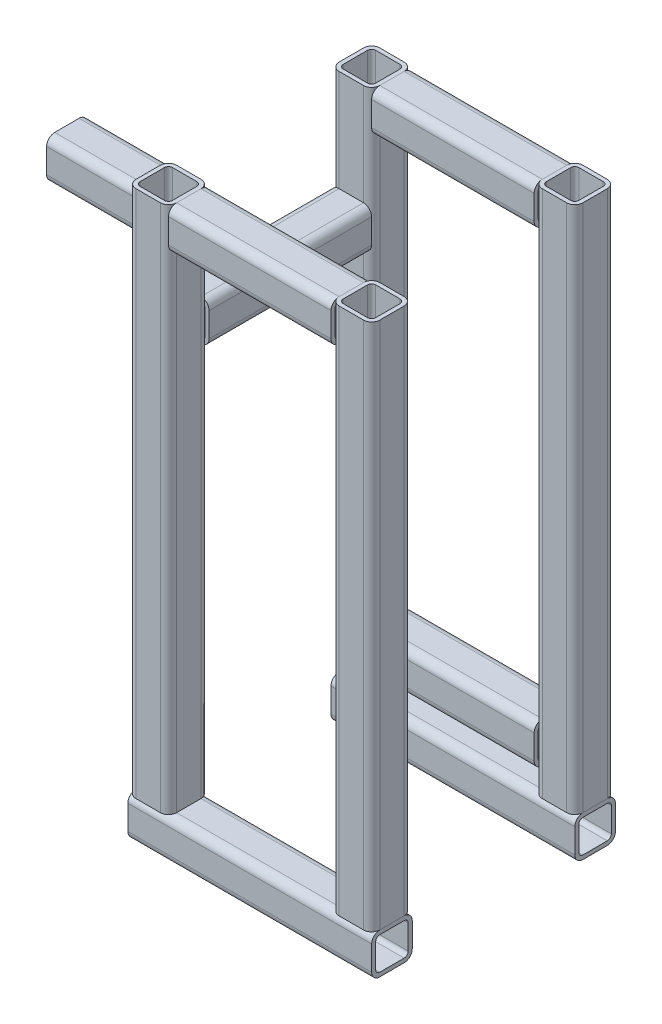
from build123d import *

# Parameters (mm, degrees)
SQUARE_TUBE_40_X_40_X_4_1_DEPTH      = 220
SQUARE_TUBE_40_X_40_X_4_1_DEPTH_BACK = 20
SQUARE_TUBE_40_X_40_X_4_1_2_DEPTH    = 240
SQUARE_TUBE_40_X_40_X_4_1_3_DEPTH    = 541
SQUARE_TUBE_40_X_40_X_4_1_4_DEPTH    = 541
SQUARE_TUBE_40_X_40_X_4_1_5_DEPTH    = 541
SQUARE_TUBE_40_X_40_X_4_1_6_DEPTH    = 541
SQUARE_TUBE_40_X_40_X_4_1_7_DEPTH    = 202
SQUARE_TUBE_40_X_40_X_4_1_8_DEPTH    = 202
SQUARE_TUBE_40_X_40_X_4_1_9_DEPTH    = 202
SQUARE_TUBE_40_X_40_X_4_1_10_DEPTH   = 201
SQUARE_TUBE_40_X_40_X_4_1_11_DEPTH   = 202


with BuildPart() as part:
    # Sketch1 → Square tube 40 X 40 X 4(1) (new, two sides)
    with BuildSketch(Plane(origin=(0, 0, 200), x_dir=(0, 0, -1), z_dir=(1, 0, 0))) as square_tube_40_x_40_x_4_1_sk:
        with BuildLine():
            Line((-12, -20), (12, -20))
            ThreePointArc((12, -20), (17.656854249, -17.656854249), (20, -12))
            Line((20, -12), (20, 12))
            ThreePointArc((20, 12), (17.656854249, 17.656854249), (12, 20))
            Line((12, 20), (-12, 20))
            ThreePointArc((-12, 20), (-17.656854249, 17.656854249), (-20, 12))
            Line((-20, 12), (-20, -12))
            ThreePointArc((-20, -12), (-17.656854249, -17.656854249), (-12, -20))
        make_face()
        with BuildLine():
            Line((-12, -16), (12, -16))
            ThreePointArc((12, -16), (14.828427125, -14.828427125), (16, -12))
            Line((16, -12), (16, 12))
            ThreePointArc((16, 12), (14.828427125, 14.828427125), (12, 16))
            Line((12, 16), (-12, 16))
            ThreePointArc((-12, 16), (-14.828427125, 14.828427125), (-16, 12))
            Line((-16, 12), (-16, -12))
            ThreePointArc((-16, -12), (-14.828427125, -14.828427125), (-12, -16))
        make_face(mode=Mode.SUBTRACT)
    extrude(amount=SQUARE_TUBE_40_X_40_X_4_1_DEPTH)
    extrude(square_tube_40_x_40_x_4_1_sk.sketch, amount=-SQUARE_TUBE_40_X_40_X_4_1_DEPTH_BACK)


with BuildPart() as body_2:
    # Sketch1 on segment 2 (carried to segment 2) → Square tube 40 X 40 X 4_1 2 (new body)
    with BuildSketch(Plane(origin=(-20, 0, 0), x_dir=(0, 0, -1), z_dir=(1, 0, 0))):
        with BuildLine():
            Line((-12, -20), (12, -20))
            ThreePointArc((12, -20), (17.656854249, -17.656854249), (20, -12))
            Line((20, -12), (20, 12))
            ThreePointArc((20, 12), (17.656854249, 17.656854249), (12, 20))
            Line((12, 20), (-12, 20))
            ThreePointArc((-12, 20), (-17.656854249, 17.656854249), (-20, 12))
            Line((-20, 12), (-20, -12))
            ThreePointArc((-20, -12), (-17.656854249, -17.656854249), (-12, -20))
        make_face()
        with BuildLine():
            Line((-12, -16), (12, -16))
            ThreePointArc((12, -16), (14.828427125, -14.828427125), (16, -12))
            Line((16, -12), (16, 12))
            ThreePointArc((16, 12), (14.828427125, 14.828427125), (12, 16))
            Line((12, 16), (-12, 16))
            ThreePointArc((-12, 16), (-14.828427125, 14.828427125), (-16, 12))
            Line((-16, 12), (-16, -12))
            ThreePointArc((-16, -12), (-14.828427125, -14.828427125), (-12, -16))
        make_face(mode=Mode.SUBTRACT)
    extrude(amount=SQUARE_TUBE_40_X_40_X_4_1_2_DEPTH)


with BuildPart() as body_3:
    # Sketch1 on segment 3 (carried to segment 3) → Square tube 40 X 40 X 4_1 3 (new body)
    with BuildSketch(Plane(origin=(0, -1, 200), x_dir=(0, 0, -1), z_dir=(0, 1, 0))):
        with BuildLine():
            Line((-12, -20), (12, -20))
            ThreePointArc((12, -20), (17.656854249, -17.656854249), (20, -12))
            Line((20, -12), (20, 12))
            ThreePointArc((20, 12), (17.656854249, 17.656854249), (12, 20))
            Line((12, 20), (-12, 20))
            ThreePointArc((-12, 20), (-17.656854249, 17.656854249), (-20, 12))
            Line((-20, 12), (-20, -12))
            ThreePointArc((-20, -12), (-17.656854249, -17.656854249), (-12, -20))
        make_face()
        with BuildLine():
            Line((-12, -16), (12, -16))
            ThreePointArc((12, -16), (14.828427125, -14.828427125), (16, -12))
            Line((16, -12), (16, 12))
            ThreePointArc((16, 12), (14.828427125, 14.828427125), (12, 16))
            Line((12, 16), (-12, 16))
            ThreePointArc((-12, 16), (-14.828427125, 14.828427125), (-16, 12))
            Line((-16, 12), (-16, -12))
            ThreePointArc((-16, -12), (-14.828427125, -14.828427125), (-12, -16))
        make_face(mode=Mode.SUBTRACT)
    extrude(amount=SQUARE_TUBE_40_X_40_X_4_1_3_DEPTH)

    # Square tube 40 X 40 X 4_1 3 end butt 1
    split(bisect_by=Plane(origin=(0, 20, 200), x_dir=(-1, 0, 0), z_dir=(0, 1, 0)), keep=Keep.TOP)


with BuildPart() as body_4:
    # Sketch1 on segment 4 (carried to segment 4) → Square tube 40 X 40 X 4_1 4 (new body)
    with BuildSketch(Plane(origin=(200, -1, 200), x_dir=(0, 0, -1), z_dir=(0, 1, 0))):
        with BuildLine():
            Line((-12, -20), (12, -20))
            ThreePointArc((12, -20), (17.656854249, -17.656854249), (20, -12))
            Line((20, -12), (20, 12))
            ThreePointArc((20, 12), (17.656854249, 17.656854249), (12, 20))
            Line((12, 20), (-12, 20))
            ThreePointArc((-12, 20), (-17.656854249, 17.656854249), (-20, 12))
            Line((-20, 12), (-20, -12))
            ThreePointArc((-20, -12), (-17.656854249, -17.656854249), (-12, -20))
        make_face()
        with BuildLine():
            Line((-12, -16), (12, -16))
            ThreePointArc((12, -16), (14.828427125, -14.828427125), (16, -12))
            Line((16, -12), (16, 12))
            ThreePointArc((16, 12), (14.828427125, 14.828427125), (12, 16))
            Line((12, 16), (-12, 16))
            ThreePointArc((-12, 16), (-14.828427125, 14.828427125), (-16, 12))
            Line((-16, 12), (-16, -12))
            ThreePointArc((-16, -12), (-14.828427125, -14.828427125), (-12, -16))
        make_face(mode=Mode.SUBTRACT)
    extrude(amount=SQUARE_TUBE_40_X_40_X_4_1_4_DEPTH)

    # Square tube 40 X 40 X 4_1 4 end butt 1
    split(bisect_by=Plane(origin=(200, 20, 200), x_dir=(-1, 0, 0), z_dir=(0, 1, 0)), keep=Keep.TOP)


with BuildPart() as body_5:
    # Sketch1 on segment 5 (carried to segment 5) → Square tube 40 X 40 X 4_1 5 (new body)
    with BuildSketch(Plane(origin=(200, -1, 0), x_dir=(0, 0, -1), z_dir=(0, 1, 0))):
        with BuildLine():
            Line((-12, -20), (12, -20))
            ThreePointArc((12, -20), (17.656854249, -17.656854249), (20, -12))
            Line((20, -12), (20, 12))
            ThreePointArc((20, 12), (17.656854249, 17.656854249), (12, 20))
            Line((12, 20), (-12, 20))
            ThreePointArc((-12, 20), (-17.656854249, 17.656854249), (-20, 12))
            Line((-20, 12), (-20, -12))
            ThreePointArc((-20, -12), (-17.656854249, -17.656854249), (-12, -20))
        make_face()
        with BuildLine():
            Line((-12, -16), (12, -16))
            ThreePointArc((12, -16), (14.828427125, -14.828427125), (16, -12))
            Line((16, -12), (16, 12))
            ThreePointArc((16, 12), (14.828427125, 14.828427125), (12, 16))
            Line((12, 16), (-12, 16))
            ThreePointArc((-12, 16), (-14.828427125, 14.828427125), (-16, 12))
            Line((-16, 12), (-16, -12))
            ThreePointArc((-16, -12), (-14.828427125, -14.828427125), (-12, -16))
        make_face(mode=Mode.SUBTRACT)
    extrude(amount=SQUARE_TUBE_40_X_40_X_4_1_5_DEPTH)

    # Square tube 40 X 40 X 4_1 5 end butt 1
    split(bisect_by=Plane(origin=(200, 20, 0), x_dir=(-1, 0, 0), z_dir=(0, 1, 0)), keep=Keep.TOP)


with BuildPart() as body_6:
    # Sketch1 on segment 6 (carried to segment 6) → Square tube 40 X 40 X 4_1 6 (new body)
    with BuildSketch(Plane(origin=(0, -1, 0), x_dir=(0, 0, -1), z_dir=(0, 1, 0))):
        with BuildLine():
            Line((-12, -20), (12, -20))
            ThreePointArc((12, -20), (17.656854249, -17.656854249), (20, -12))
            Line((20, -12), (20, 12))
            ThreePointArc((20, 12), (17.656854249, 17.656854249), (12, 20))
            Line((12, 20), (-12, 20))
            ThreePointArc((-12, 20), (-17.656854249, 17.656854249), (-20, 12))
            Line((-20, 12), (-20, -12))
            ThreePointArc((-20, -12), (-17.656854249, -17.656854249), (-12, -20))
        make_face()
        with BuildLine():
            Line((-12, -16), (12, -16))
            ThreePointArc((12, -16), (14.828427125, -14.828427125), (16, -12))
            Line((16, -12), (16, 12))
            ThreePointArc((16, 12), (14.828427125, 14.828427125), (12, 16))
            Line((12, 16), (-12, 16))
            ThreePointArc((-12, 16), (-14.828427125, 14.828427125), (-16, 12))
            Line((-16, 12), (-16, -12))
            ThreePointArc((-16, -12), (-14.828427125, -14.828427125), (-12, -16))
        make_face(mode=Mode.SUBTRACT)
    extrude(amount=SQUARE_TUBE_40_X_40_X_4_1_6_DEPTH)

    # Square tube 40 X 40 X 4_1 6 end butt 1
    split(bisect_by=Plane(origin=(0, 20, 0), x_dir=(-1, 0, 0), z_dir=(0, 1, 0)), keep=Keep.TOP)


with BuildPart() as body_7:
    # Sketch1 on segment 7 (carried to segment 7) → Square tube 40 X 40 X 4_1 7 (new body)
    with BuildSketch(Plane(origin=(-1, 520, 0), x_dir=(0, 0, -1), z_dir=(1, 0, 0))):
        with BuildLine():
            Line((-12, -20), (12, -20))
            ThreePointArc((12, -20), (17.656854249, -17.656854249), (20, -12))
            Line((20, -12), (20, 12))
            ThreePointArc((20, 12), (17.656854249, 17.656854249), (12, 20))
            Line((12, 20), (-12, 20))
            ThreePointArc((-12, 20), (-17.656854249, 17.656854249), (-20, 12))
            Line((-20, 12), (-20, -12))
            ThreePointArc((-20, -12), (-17.656854249, -17.656854249), (-12, -20))
        make_face()
        with BuildLine():
            Line((-12, -16), (12, -16))
            ThreePointArc((12, -16), (14.828427125, -14.828427125), (16, -12))
            Line((16, -12), (16, 12))
            ThreePointArc((16, 12), (14.828427125, 14.828427125), (12, 16))
            Line((12, 16), (-12, 16))
            ThreePointArc((-12, 16), (-14.828427125, 14.828427125), (-16, 12))
            Line((-16, 12), (-16, -12))
            ThreePointArc((-16, -12), (-14.828427125, -14.828427125), (-12, -16))
        make_face(mode=Mode.SUBTRACT)
    extrude(amount=SQUARE_TUBE_40_X_40_X_4_1_7_DEPTH)

    # Square tube 40 X 40 X 4_1 7 end butt 1
    split(bisect_by=Plane(origin=(20, 520, 0), x_dir=(0, 1, 0), z_dir=(1, 0, 0)), keep=Keep.TOP)

    # Square tube 40 X 40 X 4_1 7 end butt 2
    split(bisect_by=Plane(origin=(180, 520, 0), x_dir=(0, -1, 0), z_dir=(-1, 0, 0)), keep=Keep.TOP)


with BuildPart() as body_8:
    # Sketch1 on segment 8 (carried to segment 8) → Square tube 40 X 40 X 4_1 8 (new body)
    with BuildSketch(Plane(origin=(-1, 520, 200), x_dir=(0, 0, -1), z_dir=(1, 0, 0))):
        with BuildLine():
            Line((-12, -20), (12, -20))
            ThreePointArc((12, -20), (17.656854249, -17.656854249), (20, -12))
            Line((20, -12), (20, 12))
            ThreePointArc((20, 12), (17.656854249, 17.656854249), (12, 20))
            Line((12, 20), (-12, 20))
            ThreePointArc((-12, 20), (-17.656854249, 17.656854249), (-20, 12))
            Line((-20, 12), (-20, -12))
            ThreePointArc((-20, -12), (-17.656854249, -17.656854249), (-12, -20))
        make_face()
        with BuildLine():
            Line((-12, -16), (12, -16))
            ThreePointArc((12, -16), (14.828427125, -14.828427125), (16, -12))
            Line((16, -12), (16, 12))
            ThreePointArc((16, 12), (14.828427125, 14.828427125), (12, 16))
            Line((12, 16), (-12, 16))
            ThreePointArc((-12, 16), (-14.828427125, 14.828427125), (-16, 12))
            Line((-16, 12), (-16, -12))
            ThreePointArc((-16, -12), (-14.828427125, -14.828427125), (-12, -16))
        make_face(mode=Mode.SUBTRACT)
    extrude(amount=SQUARE_TUBE_40_X_40_X_4_1_8_DEPTH)

    # Square tube 40 X 40 X 4_1 8 end butt 1
    split(bisect_by=Plane(origin=(20, 520, 200), x_dir=(0, 1, 0), z_dir=(1, 0, 0)), keep=Keep.TOP)

    # Square tube 40 X 40 X 4_1 8 end butt 2
    split(bisect_by=Plane(origin=(180, 520, 200), x_dir=(0, -1, 0), z_dir=(-1, 0, 0)), keep=Keep.TOP)


with BuildPart() as body_9:
    # Sketch1 on segment 9 (carried to segment 9) → Square tube 40 X 40 X 4_1 9 (new body)
    with BuildSketch(Plane(origin=(0, 420, 201), x_dir=(-1, 0, 0), z_dir=(0, 0, -1))):
        with BuildLine():
            Line((-12, -20), (12, -20))
            ThreePointArc((12, -20), (17.656854249, -17.656854249), (20, -12))
            Line((20, -12), (20, 12))
            ThreePointArc((20, 12), (17.656854249, 17.656854249), (12, 20))
            Line((12, 20), (-12, 20))
            ThreePointArc((-12, 20), (-17.656854249, 17.656854249), (-20, 12))
            Line((-20, 12), (-20, -12))
            ThreePointArc((-20, -12), (-17.656854249, -17.656854249), (-12, -20))
        make_face()
        with BuildLine():
            Line((-12, -16), (12, -16))
            ThreePointArc((12, -16), (14.828427125, -14.828427125), (16, -12))
            Line((16, -12), (16, 12))
            ThreePointArc((16, 12), (14.828427125, 14.828427125), (12, 16))
            Line((12, 16), (-12, 16))
            ThreePointArc((-12, 16), (-14.828427125, 14.828427125), (-16, 12))
            Line((-16, 12), (-16, -12))
            ThreePointArc((-16, -12), (-14.828427125, -14.828427125), (-12, -16))
        make_face(mode=Mode.SUBTRACT)
    extrude(amount=SQUARE_TUBE_40_X_40_X_4_1_9_DEPTH)

    # Square tube 40 X 40 X 4_1 9 end butt 1
    split(bisect_by=Plane(origin=(0, 420, 180), x_dir=(0, 1, 0), z_dir=(0, 0, -1)), keep=Keep.TOP)

    # Square tube 40 X 40 X 4_1 9 end butt 2
    split(bisect_by=Plane(origin=(0, 420, 20), x_dir=(0, -1, 0), z_dir=(0, 0, 1)), keep=Keep.TOP)


with BuildPart() as body_10:
    # Sketch1 on segment 10 (carried to segment 10) → Square tube 40 X 40 X 4_1 10 (new body)
    with BuildSketch(Plane(origin=(-200, 420, 100), x_dir=(0, 0, -1), z_dir=(1, 0, 0))):
        with BuildLine():
            Line((-12, -20), (12, -20))
            ThreePointArc((12, -20), (17.656854249, -17.656854249), (20, -12))
            Line((20, -12), (20, 12))
            ThreePointArc((20, 12), (17.656854249, 17.656854249), (12, 20))
            Line((12, 20), (-12, 20))
            ThreePointArc((-12, 20), (-17.656854249, 17.656854249), (-20, 12))
            Line((-20, 12), (-20, -12))
            ThreePointArc((-20, -12), (-17.656854249, -17.656854249), (-12, -20))
        make_face()
        with BuildLine():
            Line((-12, -16), (12, -16))
            ThreePointArc((12, -16), (14.828427125, -14.828427125), (16, -12))
            Line((16, -12), (16, 12))
            ThreePointArc((16, 12), (14.828427125, 14.828427125), (12, 16))
            Line((12, 16), (-12, 16))
            ThreePointArc((-12, 16), (-14.828427125, 14.828427125), (-16, 12))
            Line((-16, 12), (-16, -12))
            ThreePointArc((-16, -12), (-14.828427125, -14.828427125), (-12, -16))
        make_face(mode=Mode.SUBTRACT)
    extrude(amount=SQUARE_TUBE_40_X_40_X_4_1_10_DEPTH)

    # Square tube 40 X 40 X 4_1 10 end butt 1
    split(bisect_by=Plane(origin=(-20, 420, 100), x_dir=(0, -1, 0), z_dir=(-1, 0, 0)), keep=Keep.TOP)


with BuildPart() as body_11:
    # Sketch1 on segment 11 (carried to segment 11) → Square tube 40 X 40 X 4_1 11 (new body)
    with BuildSketch(Plane(origin=(-1, 60, 0), x_dir=(0, 0, -1), z_dir=(1, 0, 0))):
        with BuildLine():
            Line((-12, -20), (12, -20))
            ThreePointArc((12, -20), (17.656854249, -17.656854249), (20, -12))
            Line((20, -12), (20, 12))
            ThreePointArc((20, 12), (17.656854249, 17.656854249), (12, 20))
            Line((12, 20), (-12, 20))
            ThreePointArc((-12, 20), (-17.656854249, 17.656854249), (-20, 12))
            Line((-20, 12), (-20, -12))
            ThreePointArc((-20, -12), (-17.656854249, -17.656854249), (-12, -20))
        make_face()
        with BuildLine():
            Line((-12, -16), (12, -16))
            ThreePointArc((12, -16), (14.828427125, -14.828427125), (16, -12))
            Line((16, -12), (16, 12))
            ThreePointArc((16, 12), (14.828427125, 14.828427125), (12, 16))
            Line((12, 16), (-12, 16))
            ThreePointArc((-12, 16), (-14.828427125, 14.828427125), (-16, 12))
            Line((-16, 12), (-16, -12))
            ThreePointArc((-16, -12), (-14.828427125, -14.828427125), (-12, -16))
        make_face(mode=Mode.SUBTRACT)
    extrude(amount=SQUARE_TUBE_40_X_40_X_4_1_11_DEPTH)

    # Square tube 40 X 40 X 4_1 11 end butt 1
    split(bisect_by=Plane(origin=(180, 60, 0), x_dir=(0, -1, 0), z_dir=(-1, 0, 0)), keep=Keep.TOP)

    # Square tube 40 X 40 X 4_1 11 end butt 2
    split(bisect_by=Plane(origin=(20, 60, 0), x_dir=(0, 1, 0), z_dir=(1, 0, 0)), keep=Keep.TOP)


solid = Compound([part.part, body_2.part, body_3.part, body_4.part, body_5.part, body_6.part, body_7.part, body_8.part, body_9.part, body_10.part, body_11.part])
